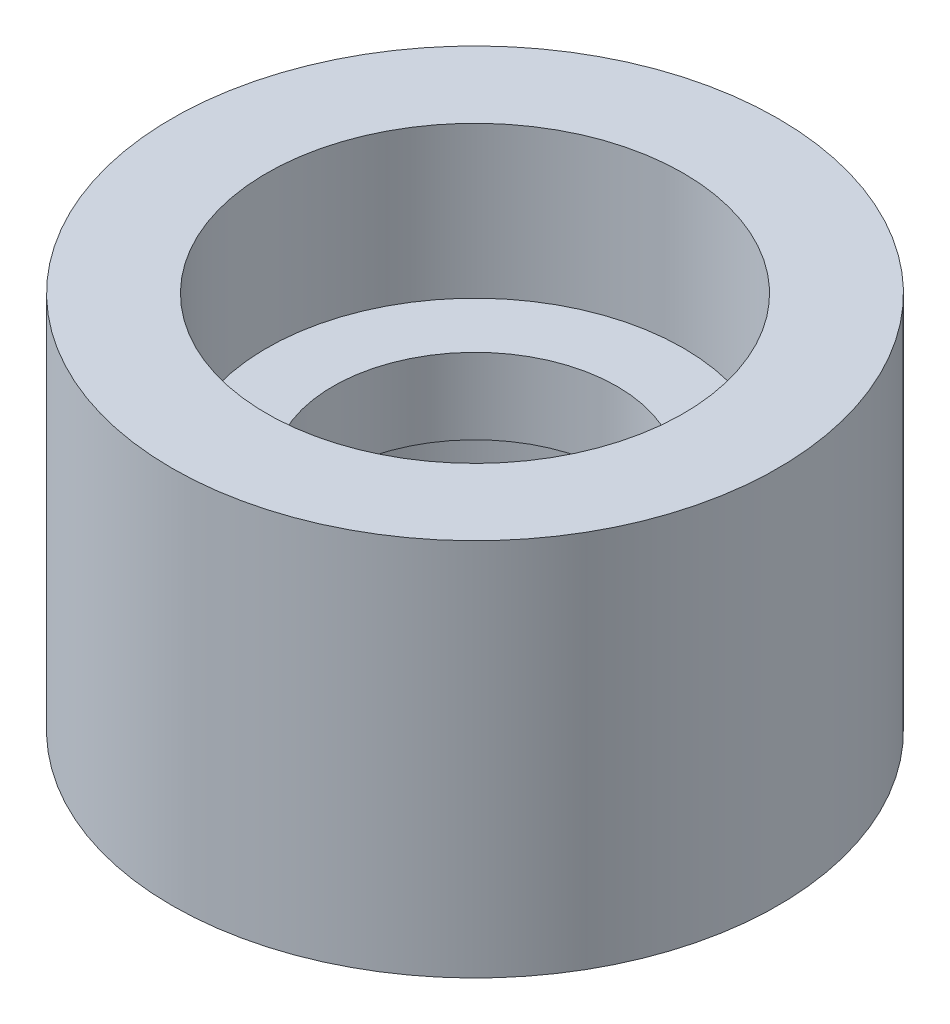
from build123d import *


with BuildPart() as part:
    # Sketch4 → Revolve1 (revolve)
    with BuildSketch(Plane.XY):
        Polygon((-11, 0), (-16, 0), (-16, 20), (-11, 20), (-11, 12), (-7.5, 12), (-7.5, 8), (-11, 8), align=None)
    revolve(axis=Axis((0, 0, 0), (0, 1, 0)))


solid = part.part
